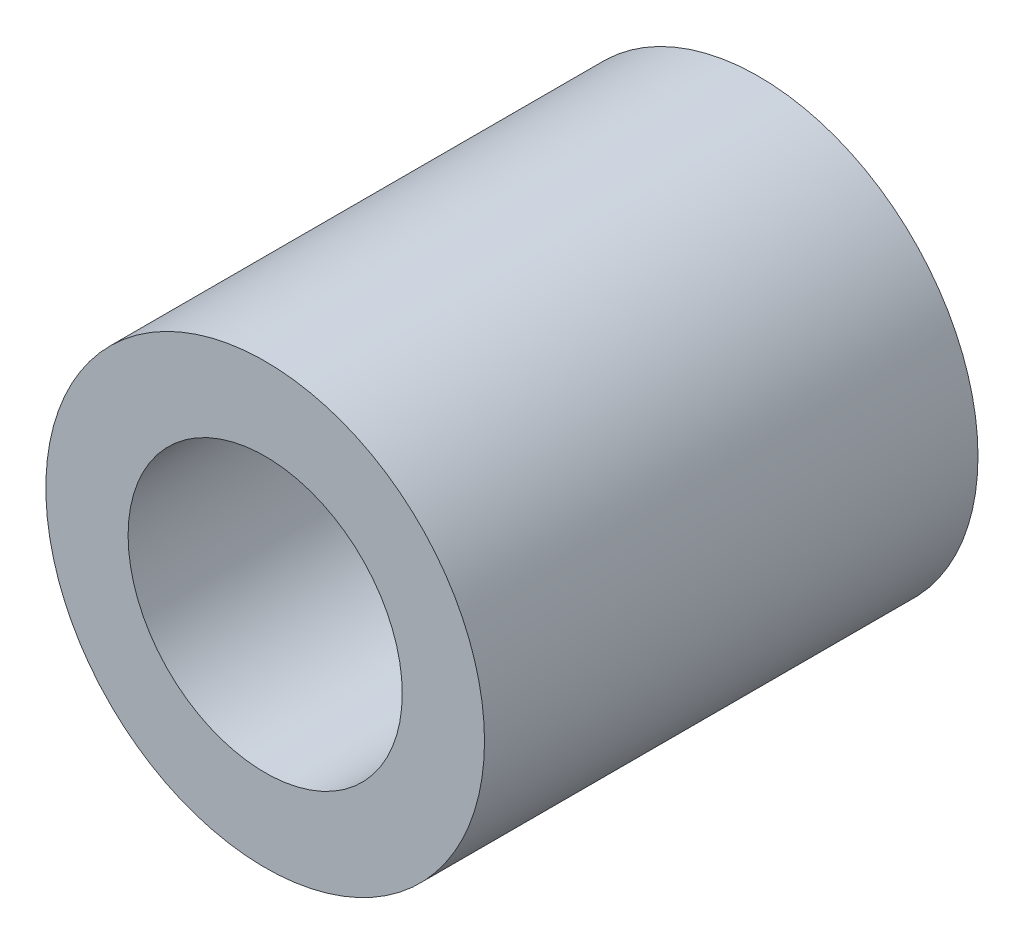
from build123d import *

# Parameters (mm, degrees)
CROQUIS1_R              = 8
CROQUIS1_R_2            = 5
SALIENTE_EXTRUIR1_DEPTH = 18


with BuildPart() as part:
    # Croquis1 → Saliente-Extruir1 (new body)
    with BuildSketch(Plane.XY):
        Circle(CROQUIS1_R)
        Circle(CROQUIS1_R_2, mode=Mode.SUBTRACT)
    extrude(amount=SALIENTE_EXTRUIR1_DEPTH)


solid = part.part
